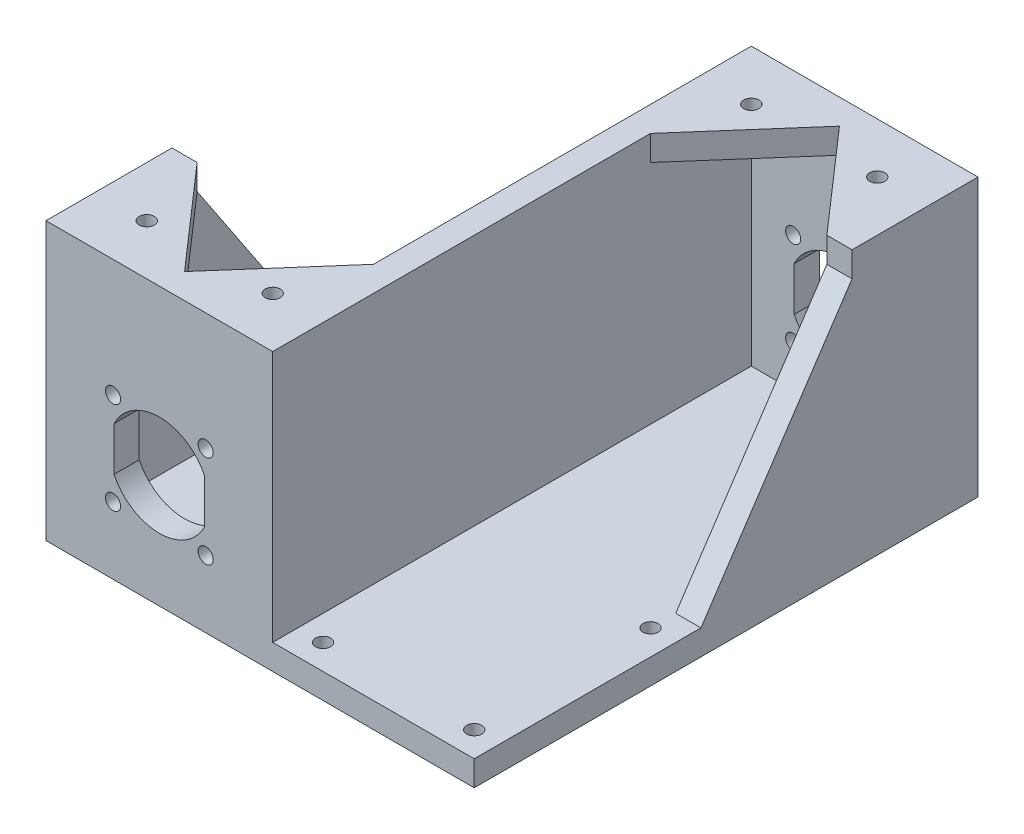
from build123d import *

# Parameters (mm, degrees)
ESQUISSE1_R             = 1.5
EXTRUSION1_DEPTH        = 5
ESQUISSE2_W             = 45
ESQUISSE2_H             = 5
EXTRUSION2_DEPTH        = 95
EXTRUSION3_DEPTH        = 5
ESQUISSE4_W             = 95
ESQUISSE4_H             = 50
EXTRUSION4_DEPTH        = 5
ESQUISSE5_W             = 100
ESQUISSE5_H             = 5
EXTRUSION5_DEPTH        = 40
ESQUISSE6_W             = 40
ESQUISSE6_H             = 50
EXTRUSION6_DEPTH        = 5
EXTRUSION7_DEPTH        = 5
ENL_V_MAT_EXTRU_1_REACH = 102
ESQUISSE8_R             = 1.5
ENL_V_MAT_EXTRU_2_REACH = 7
ESQUISSE9_R             = 1.5
BOSS_EXTRU_1_DEPTH      = 5
BOSS_EXTRU_2_DEPTH      = 5
ESQUISSE16_R            = 1.5
ENL_V_MAT_EXTRU_3_DEPTH = 4


with BuildPart() as part:
    # Esquisse1 → Extrusion1 (new body)
    with BuildSketch(Plane.XY):
        Polygon((0, 0), (45, 0), (45, 45), (45, 55), (0, 55), (0, 45), align=None)
        with Locations((31.692388155, 31.692388155)):
            Circle(ESQUISSE1_R, mode=Mode.SUBTRACT)
        with Locations((31.692388155, 13.307611845)):
            Circle(ESQUISSE1_R, mode=Mode.SUBTRACT)
        with Locations((13.307611845, 13.307611845)):
            Circle(ESQUISSE1_R, mode=Mode.SUBTRACT)
        with Locations((13.307611845, 31.692388155)):
            Circle(ESQUISSE1_R, mode=Mode.SUBTRACT)
        with BuildLine():
            Line((13.5, 26.858898944), (13.5, 18.141101056))
            ThreePointArc((13.5, 18.141101056), (22.5, 12.5), (31.5, 18.141101056))
            Line((31.5, 18.141101056), (31.5, 26.858898944))
            ThreePointArc((31.5, 26.858898944), (22.5, 32.5), (13.5, 26.858898944))
        make_face(mode=Mode.SUBTRACT)
    extrude(amount=EXTRUSION1_DEPTH)

    # Esquisse2 → Extrusion2 (add)
    with BuildSketch(Plane.XY.offset(5)):
        with Locations((22.5, 2.5)):
            Rectangle(ESQUISSE2_W, ESQUISSE2_H)
    extrude(amount=EXTRUSION2_DEPTH)

    # Esquisse3 → Extrusion3 (add)
    with BuildSketch(Plane(origin=(45, 0, 0), x_dir=(0, 0, -1), z_dir=(1, 0, 0))):
        Polygon((-5, 5), (-5, 55), (-25, 55), (-25, 50), (-55, 5), align=None)
    extrude(amount=-EXTRUSION3_DEPTH)

    # Esquisse4 → Extrusion4 (add)
    with BuildSketch(Plane.ZY):
        with Locations((52.5, 30)):
            Rectangle(ESQUISSE4_W, ESQUISSE4_H)
    extrude(amount=-EXTRUSION4_DEPTH)

    # Esquisse5 → Extrusion5 (add)
    with BuildSketch(Plane.ZY):
        with Locations((50, 2.5)):
            Rectangle(ESQUISSE5_W, ESQUISSE5_H)
    extrude(amount=EXTRUSION5_DEPTH)

    # Esquisse6 → Extrusion6 (add)
    with BuildSketch(Plane.XY.offset(100)):
        with Locations((-20, 30)):
            Rectangle(ESQUISSE6_W, ESQUISSE6_H)
    extrude(amount=-EXTRUSION6_DEPTH)

    # Esquisse7 → Extrusion7 (add)
    with BuildSketch(Plane.ZY.offset(40)):
        Polygon((95, 5), (95, 55), (75, 55), (75, 50), (45, 5), align=None)
    extrude(amount=-EXTRUSION7_DEPTH)

    # Esquisse8 → Enlèv. mat.-Extru.1 (cut, up to next)
    with BuildSketch(Plane.XY.offset(100), mode=Mode.PRIVATE) as enl_v_mat_extru_1_sk1:
        with Locations((-8.307611845, 13.307611845)):
            Circle(ESQUISSE8_R)
    enl_v_mat_extru_1_tool1 = extrude(enl_v_mat_extru_1_sk1.sketch, amount=-ENL_V_MAT_EXTRU_1_REACH, mode=Mode.PRIVATE) & part.part
    add(enl_v_mat_extru_1_tool1.solids().sort_by_distance((-8.307612, 13.307612, 100))[0], mode=Mode.SUBTRACT)
    # Esquisse8 → Enlèv. mat.-Extru.1 (cut, up to next)
    with BuildSketch(Plane.XY.offset(100), mode=Mode.PRIVATE) as enl_v_mat_extru_1_sk2:
        with Locations((-8.307611845, 31.692388155)):
            Circle(ESQUISSE8_R)
    enl_v_mat_extru_1_tool2 = extrude(enl_v_mat_extru_1_sk2.sketch, amount=-ENL_V_MAT_EXTRU_1_REACH, mode=Mode.PRIVATE) & part.part
    add(enl_v_mat_extru_1_tool2.solids().sort_by_distance((-8.307612, 31.692388, 100))[0], mode=Mode.SUBTRACT)
    # Esquisse8 → Enlèv. mat.-Extru.1 (cut, up to next)
    with BuildSketch(Plane.XY.offset(100), mode=Mode.PRIVATE) as enl_v_mat_extru_1_sk3:
        with Locations((-26.692388155, 31.692388155)):
            Circle(ESQUISSE8_R)
    enl_v_mat_extru_1_tool3 = extrude(enl_v_mat_extru_1_sk3.sketch, amount=-ENL_V_MAT_EXTRU_1_REACH, mode=Mode.PRIVATE) & part.part
    add(enl_v_mat_extru_1_tool3.solids().sort_by_distance((-26.692388, 31.692388, 100))[0], mode=Mode.SUBTRACT)
    # Esquisse8 → Enlèv. mat.-Extru.1 (cut, up to next)
    with BuildSketch(Plane.XY.offset(100), mode=Mode.PRIVATE) as enl_v_mat_extru_1_sk4:
        with Locations((-26.692388155, 13.307611845)):
            Circle(ESQUISSE8_R)
    enl_v_mat_extru_1_tool4 = extrude(enl_v_mat_extru_1_sk4.sketch, amount=-ENL_V_MAT_EXTRU_1_REACH, mode=Mode.PRIVATE) & part.part
    add(enl_v_mat_extru_1_tool4.solids().sort_by_distance((-26.692388, 13.307612, 100))[0], mode=Mode.SUBTRACT)
    # Esquisse8 → Enlèv. mat.-Extru.1 (cut, up to next)
    with BuildSketch(Plane.XY.offset(100), mode=Mode.PRIVATE) as enl_v_mat_extru_1_sk5:
        with BuildLine():
            Line((-26.5, 18.141101056), (-26.5, 26.858898944))
            ThreePointArc((-26.5, 26.858898944), (-17.5, 32.5), (-8.5, 26.858898944))
            Line((-8.5, 26.858898944), (-8.5, 18.141101056))
            ThreePointArc((-8.5, 18.141101056), (-17.5, 12.5), (-26.5, 18.141101056))
        make_face()
    enl_v_mat_extru_1_tool5 = extrude(enl_v_mat_extru_1_sk5.sketch, amount=-ENL_V_MAT_EXTRU_1_REACH, mode=Mode.PRIVATE) & part.part
    add(enl_v_mat_extru_1_tool5.solids().sort_by_distance((-17.5, 22.5, 100))[0], mode=Mode.SUBTRACT)

    # Esquisse9 → Enlèv. mat.-Extru.2 (cut, up to next)
    with BuildSketch(Plane(origin=(0, 5, 0), x_dir=(-1, 0, 0), z_dir=(0, 1, 0)), mode=Mode.PRIVATE) as enl_v_mat_extru_2_sk1:
        with Locations((-40, 95)):
            Circle(ESQUISSE9_R)
    enl_v_mat_extru_2_tool1 = extrude(enl_v_mat_extru_2_sk1.sketch, amount=-ENL_V_MAT_EXTRU_2_REACH, mode=Mode.PRIVATE) & part.part
    add(enl_v_mat_extru_2_tool1.solids().sort_by_distance((40, 5, 95))[0], mode=Mode.SUBTRACT)
    # Esquisse9 → Enlèv. mat.-Extru.2 (cut, up to next)
    with BuildSketch(Plane(origin=(0, 5, 0), x_dir=(-1, 0, 0), z_dir=(0, 1, 0)), mode=Mode.PRIVATE) as enl_v_mat_extru_2_sk2:
        with Locations((-10, 95)):
            Circle(ESQUISSE9_R)
    enl_v_mat_extru_2_tool2 = extrude(enl_v_mat_extru_2_sk2.sketch, amount=-ENL_V_MAT_EXTRU_2_REACH, mode=Mode.PRIVATE) & part.part
    add(enl_v_mat_extru_2_tool2.solids().sort_by_distance((10, 5, 95))[0], mode=Mode.SUBTRACT)
    # Esquisse9 → Enlèv. mat.-Extru.2 (cut, up to next)
    with BuildSketch(Plane(origin=(0, 5, 0), x_dir=(-1, 0, 0), z_dir=(0, 1, 0)), mode=Mode.PRIVATE) as enl_v_mat_extru_2_sk3:
        with Locations((35, 5)):
            Circle(ESQUISSE9_R)
    enl_v_mat_extru_2_tool3 = extrude(enl_v_mat_extru_2_sk3.sketch, amount=-ENL_V_MAT_EXTRU_2_REACH, mode=Mode.PRIVATE) & part.part
    add(enl_v_mat_extru_2_tool3.solids().sort_by_distance((-35, 5, 5))[0], mode=Mode.SUBTRACT)
    # Esquisse9 → Enlèv. mat.-Extru.2 (cut, up to next)
    with BuildSketch(Plane(origin=(0, 5, 0), x_dir=(-1, 0, 0), z_dir=(0, 1, 0)), mode=Mode.PRIVATE) as enl_v_mat_extru_2_sk4:
        with Locations((5, 5)):
            Circle(ESQUISSE9_R)
    enl_v_mat_extru_2_tool4 = extrude(enl_v_mat_extru_2_sk4.sketch, amount=-ENL_V_MAT_EXTRU_2_REACH, mode=Mode.PRIVATE) & part.part
    add(enl_v_mat_extru_2_tool4.solids().sort_by_distance((-5, 5, 5))[0], mode=Mode.SUBTRACT)
    # Esquisse9 → Enlèv. mat.-Extru.2 (cut, up to next)
    with BuildSketch(Plane(origin=(0, 5, 0), x_dir=(-1, 0, 0), z_dir=(0, 1, 0)), mode=Mode.PRIVATE) as enl_v_mat_extru_2_sk5:
        with Locations((-40, 60)):
            Circle(ESQUISSE9_R)
    enl_v_mat_extru_2_tool5 = extrude(enl_v_mat_extru_2_sk5.sketch, amount=-ENL_V_MAT_EXTRU_2_REACH, mode=Mode.PRIVATE) & part.part
    add(enl_v_mat_extru_2_tool5.solids().sort_by_distance((40, 5, 60))[0], mode=Mode.SUBTRACT)
    # Esquisse9 → Enlèv. mat.-Extru.2 (cut, up to next)
    with BuildSketch(Plane(origin=(0, 5, 0), x_dir=(-1, 0, 0), z_dir=(0, 1, 0)), mode=Mode.PRIVATE) as enl_v_mat_extru_2_sk6:
        with Locations((35, 40)):
            Circle(ESQUISSE9_R)
    enl_v_mat_extru_2_tool6 = extrude(enl_v_mat_extru_2_sk6.sketch, amount=-ENL_V_MAT_EXTRU_2_REACH, mode=Mode.PRIVATE) & part.part
    add(enl_v_mat_extru_2_tool6.solids().sort_by_distance((-35, 5, 40))[0], mode=Mode.SUBTRACT)

    # Esquisse11 → Boss.-Extru.1 (add)
    with BuildSketch(Plane(origin=(0, 55, 0), x_dir=(1, 0, 0), z_dir=(0, 1, 0))):
        Polygon((22.5, -5), (5, -25), (5, 0), (40, 0), (40, -25), align=None)
    extrude(amount=-BOSS_EXTRU_1_DEPTH)

    # Esquisse12 → Boss.-Extru.2 (add)
    with BuildSketch(Plane(origin=(0, 55, 0), x_dir=(1, 0, 0), z_dir=(0, 1, 0))):
        Polygon((0, -75), (-17.5, -95), (-35, -75), (-35, -100), (0, -100), align=None)
    extrude(amount=-BOSS_EXTRU_2_DEPTH)

    # Esquisse16 → Enlèv. mat.-Extru.3 (cut)
    with BuildSketch(Plane(origin=(0, 55, 0), x_dir=(1, 0, 0), z_dir=(0, 1, 0))):
        with Locations((-5, -90)):
            Circle(ESQUISSE16_R)
        with Locations((-30, -90)):
            Circle(ESQUISSE16_R)
        with Locations((10, -10)):
            Circle(ESQUISSE16_R)
        with Locations((35, -10)):
            Circle(ESQUISSE16_R)
    extrude(amount=-ENL_V_MAT_EXTRU_3_DEPTH, mode=Mode.SUBTRACT)


solid = part.part
